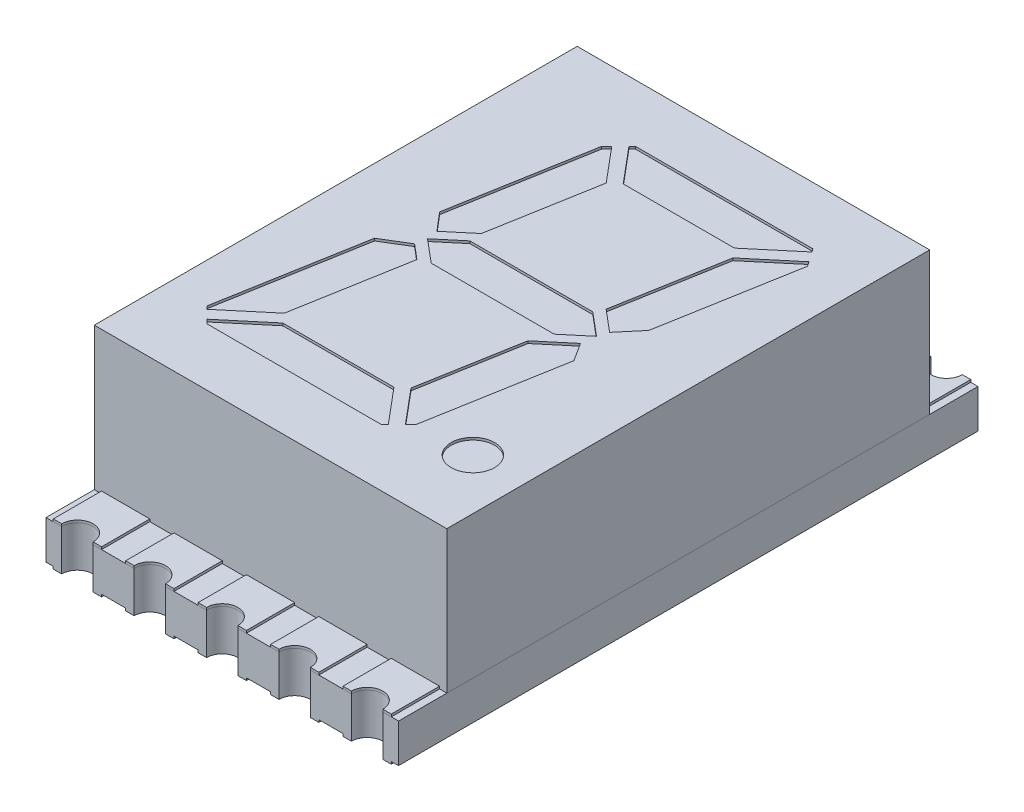
from build123d import *

# Parameters (mm, degrees)
SKETCH1_W          = 7.3
SKETCH1_H          = 10
EXTRUDE1_DEPTH     = 2.95
SKETCH6_R          = 0.45
CUT_EXTRUDE1_DEPTH = 0.05
SKETCH9_W          = 7.3
SKETCH9_H          = 12
EXTRUDE2_DEPTH     = 0.8
EXTRUDE3_DEPTH     = 0.05
EXTRUDE3_2_DEPTH   = 0.05
EXTRUDE3_3_DEPTH   = 0.05
EXTRUDE3_4_DEPTH   = 0.05
EXTRUDE3_5_DEPTH   = 0.05
EXTRUDE3_6_DEPTH   = 0.05
EXTRUDE3_7_DEPTH   = 0.05
EXTRUDE3_8_DEPTH   = 0.05
EXTRUDE3_9_DEPTH   = 0.05
EXTRUDE3_10_DEPTH  = 0.05
SKETCH11_W         = 1
SKETCH11_H         = 1.3
EXTRUDE4_DEPTH     = 0.05
SKETCH10_5_R       = 0.325
CUT_EXTRUDE2_DEPTH = 1.85


with BuildPart() as part:
    # Sketch1 → Extrude1 (new body)
    with BuildSketch(Plane(origin=(0, 0, 0), x_dir=(1, 0, 0), z_dir=(0, 1, 0))):
        Rectangle(SKETCH1_W, SKETCH1_H)
    extrude(amount=-EXTRUDE1_DEPTH)

    # Sketch6 → Cut-Extrude1 (cut)
    with BuildSketch(Plane(origin=(0, 0, 0), x_dir=(-1, 0, 0), z_dir=(0, 1, 0))):
        Polygon((1.497133821, -3.562928938), (1.603616149, -3.456446609), (2.106021692, -0.607163185), (1.786018363, -0.230858463), (1.28606151, -0.650372074), (0.898330642, -2.849303098), align=None)
        Polygon((1.250062758, -3.81), (1.319681867, -3.740380891), (0.706819531, -3.01), (-1.595956803, -3.01), (-2.468328033, -3.742006377), (-2.420718386, -3.81), align=None)
        Polygon((1.792236167, 0.225641106), (2.308170181, 0.539277865), (2.828779838, 3.491801948), (2.77008652, 3.550495267), (1.89771529, 2.818488889), (1.485856892, 0.482723843), align=None)
        Polygon((1.273298563, -0.4), (1.75, 0), (1.273298563, 0.4), (-1.273298563, 0.4), (-1.75, 0), (-1.273298563, -0.4), align=None)
        Polygon((-2.612269884, -3.536436109), (-1.756653705, -2.818488889), (-1.362976227, -0.585832963), (-1.815546448, -0.206081458), (-2.186257722, -0.647877951), (-2.678827782, -3.44138158), align=None)
        Polygon((1.737018387, 3.01), (2.592634566, 3.72794722), (2.510581787, 3.81), (-1.109001174, 3.81), (-1.178620283, 3.740380891), (-0.565757946, 3.01), align=None)
        Polygon((-1.712086694, 0.292894499), (-1.120504838, 0.789290616), (-0.757269057, 2.849303098), (-1.356072236, 3.562928938), (-1.462554564, 3.456446609), (-1.953419115, 0.672615404), align=None)
        with Locations(Location((-2.6, 3.41, 0), (0, 0, 90))):  # turned: the seam where the file's is
            Circle(SKETCH6_R)
    extrude(amount=-CUT_EXTRUDE1_DEPTH, mode=Mode.SUBTRACT)


with BuildPart() as body_2:
    # Sketch9 → Extrude2 (new body)
    with BuildSketch(Plane.XZ.offset(2.95)):
        Rectangle(SKETCH9_W, SKETCH9_H)
    extrude(amount=EXTRUDE2_DEPTH)

    # Sketch11 → Extrude4 (add)
    with BuildSketch(Plane.XZ.offset(3.75)):
        with Locations((-3, 5.35)):
            Rectangle(SKETCH11_W, SKETCH11_H)
        with Locations((-1.5, 5.35)):
            Rectangle(SKETCH11_W, SKETCH11_H)
        with Locations((1.5, 5.35)):
            Rectangle(SKETCH11_W, SKETCH11_H)
        with Locations((0, 5.35)):
            Rectangle(SKETCH11_W, SKETCH11_H)
        with Locations((3, 5.35)):
            Rectangle(SKETCH11_W, SKETCH11_H)
        with Locations((-3, -5.35)):
            Rectangle(SKETCH11_W, SKETCH11_H)
        with Locations((-1.5, -5.35)):
            Rectangle(SKETCH11_W, SKETCH11_H)
        with Locations((0, -5.35)):
            Rectangle(SKETCH11_W, SKETCH11_H)
        with Locations((1.5, -5.35)):
            Rectangle(SKETCH11_W, SKETCH11_H)
        with Locations((3, -5.35)):
            Rectangle(SKETCH11_W, SKETCH11_H)
    extrude(amount=EXTRUDE4_DEPTH)

    # Sketch10_5 → Cut-Extrude2 (cut, through all)
    with BuildSketch(Plane(origin=(0, -2.95, 0), x_dir=(-1, 0, 0), z_dir=(0, 1, 0))):
        with Locations((3, 6)):
            Circle(SKETCH10_5_R)
        with Locations((1.5, 6)):
            Circle(SKETCH10_5_R)
        with Locations((0, 6)):
            Circle(SKETCH10_5_R)
        with Locations((-1.5, 6)):
            Circle(SKETCH10_5_R)
        with Locations((-3, 6)):
            Circle(SKETCH10_5_R)
        with Locations((-3, -6)):
            Circle(SKETCH10_5_R)
        with Locations((-1.5, -6)):
            Circle(SKETCH10_5_R)
        with Locations((0, -6)):
            Circle(SKETCH10_5_R)
        with Locations((1.5, -6)):
            Circle(SKETCH10_5_R)
        with Locations((3, -6)):
            Circle(SKETCH10_5_R)
    extrude(amount=-CUT_EXTRUDE2_DEPTH, mode=Mode.SUBTRACT)


with BuildPart() as body_3:
    # Sketch10 → Extrude3 (new body)
    with BuildSketch(Plane(origin=(0, -2.95, 0), x_dir=(-1, 0, 0), z_dir=(0, 1, 0))):
        with BuildLine():
            Line((2.5, -5), (2.5, -6))
            Line((2.5, -6), (2.675, -6))
            ThreePointArc((2.675, -6), (3, -5.675), (3.325, -6))
            Line((3.325, -6), (3.5, -6))
            Line((3.5, -6), (3.5, -5))
            Line((3.5, -5), (2.5, -5))
        make_face()
    extrude(amount=EXTRUDE3_DEPTH)


with BuildPart() as body_4:
    # Sketch10 → Extrude3 2 (new body)
    with BuildSketch(Plane(origin=(0, -2.95, 0), x_dir=(-1, 0, 0), z_dir=(0, 1, 0))):
        with BuildLine():
            Line((1, -5), (1, -6))
            Line((1, -6), (1.175, -6))
            ThreePointArc((1.175, -6), (1.5, -5.675), (1.825, -6))
            Line((1.825, -6), (2, -6))
            Line((2, -6), (2, -5))
            Line((2, -5), (1, -5))
        make_face()
    extrude(amount=EXTRUDE3_2_DEPTH)


with BuildPart() as body_5:
    # Sketch10 → Extrude3 3 (new body)
    with BuildSketch(Plane(origin=(0, -2.95, 0), x_dir=(-1, 0, 0), z_dir=(0, 1, 0))):
        with BuildLine():
            Line((-0.5, -5), (-0.5, -6))
            Line((-0.5, -6), (-0.325, -6))
            ThreePointArc((-0.325, -6), (0, -5.675), (0.325, -6))
            Line((0.325, -6), (0.5, -6))
            Line((0.5, -6), (0.5, -5))
            Line((0.5, -5), (-0.5, -5))
        make_face()
    extrude(amount=EXTRUDE3_3_DEPTH)


with BuildPart() as body_6:
    # Sketch10 → Extrude3 4 (new body)
    with BuildSketch(Plane(origin=(0, -2.95, 0), x_dir=(-1, 0, 0), z_dir=(0, 1, 0))):
        with BuildLine():
            Line((-2, -5), (-2, -6))
            Line((-2, -6), (-1.825, -6))
            ThreePointArc((-1.825, -6), (-1.5, -5.675), (-1.175, -6))
            Line((-1.175, -6), (-1, -6))
            Line((-1, -6), (-1, -5))
            Line((-1, -5), (-2, -5))
        make_face()
    extrude(amount=EXTRUDE3_4_DEPTH)


with BuildPart() as body_7:
    # Sketch10 → Extrude3 5 (new body)
    with BuildSketch(Plane(origin=(0, -2.95, 0), x_dir=(-1, 0, 0), z_dir=(0, 1, 0))):
        with BuildLine():
            Line((-2.5, -5), (-3.5, -5))
            Line((-3.5, -5), (-3.5, -6))
            Line((-3.5, -6), (-3.325, -6))
            ThreePointArc((-3.325, -6), (-3, -5.675), (-2.675, -6))
            Line((-2.675, -6), (-2.5, -6))
            Line((-2.5, -6), (-2.5, -5))
        make_face()
    extrude(amount=EXTRUDE3_5_DEPTH)


with BuildPart() as body_8:
    # Sketch10 → Extrude3 6 (new body)
    with BuildSketch(Plane(origin=(0, -2.95, 0), x_dir=(-1, 0, 0), z_dir=(0, 1, 0))):
        with BuildLine():
            Line((2.5, 5), (3.5, 5))
            Line((3.5, 5), (3.5, 6))
            Line((3.5, 6), (3.325, 6))
            ThreePointArc((3.325, 6), (3, 5.675), (2.675, 6))
            Line((2.675, 6), (2.5, 6))
            Line((2.5, 6), (2.5, 5))
        make_face()
    extrude(amount=EXTRUDE3_6_DEPTH)


with BuildPart() as body_9:
    # Sketch10 → Extrude3 7 (new body)
    with BuildSketch(Plane(origin=(0, -2.95, 0), x_dir=(-1, 0, 0), z_dir=(0, 1, 0))):
        with BuildLine():
            Line((2, 5), (2, 6))
            Line((2, 6), (1.825, 6))
            ThreePointArc((1.825, 6), (1.5, 5.675), (1.175, 6))
            Line((1.175, 6), (1, 6))
            Line((1, 6), (1, 5))
            Line((1, 5), (2, 5))
        make_face()
    extrude(amount=EXTRUDE3_7_DEPTH)


with BuildPart() as body_10:
    # Sketch10 → Extrude3 8 (new body)
    with BuildSketch(Plane(origin=(0, -2.95, 0), x_dir=(-1, 0, 0), z_dir=(0, 1, 0))):
        with BuildLine():
            Line((0.5, 5), (0.5, 6))
            Line((0.5, 6), (0.325, 6))
            ThreePointArc((0.325, 6), (0, 5.675), (-0.325, 6))
            Line((-0.325, 6), (-0.5, 6))
            Line((-0.5, 6), (-0.5, 5))
            Line((-0.5, 5), (0.5, 5))
        make_face()
    extrude(amount=EXTRUDE3_8_DEPTH)


with BuildPart() as body_11:
    # Sketch10 → Extrude3 9 (new body)
    with BuildSketch(Plane(origin=(0, -2.95, 0), x_dir=(-1, 0, 0), z_dir=(0, 1, 0))):
        with BuildLine():
            Line((-1, 5), (-1, 6))
            Line((-1, 6), (-1.175, 6))
            ThreePointArc((-1.175, 6), (-1.5, 5.675), (-1.825, 6))
            Line((-1.825, 6), (-2, 6))
            Line((-2, 6), (-2, 5))
            Line((-2, 5), (-1, 5))
        make_face()
    extrude(amount=EXTRUDE3_9_DEPTH)


with BuildPart() as body_12:
    # Sketch10 → Extrude3 10 (new body)
    with BuildSketch(Plane(origin=(0, -2.95, 0), x_dir=(-1, 0, 0), z_dir=(0, 1, 0))):
        with BuildLine():
            Line((-2.5, 5), (-2.5, 6))
            Line((-2.5, 6), (-2.675, 6))
            ThreePointArc((-2.675, 6), (-3, 5.675), (-3.325, 6))
            Line((-3.325, 6), (-3.5, 6))
            Line((-3.5, 6), (-3.5, 5))
            Line((-3.5, 5), (-2.5, 5))
        make_face()
    extrude(amount=EXTRUDE3_10_DEPTH)


solid = Compound([part.part, body_2.part, body_3.part, body_4.part, body_5.part, body_6.part, body_7.part, body_8.part, body_9.part, body_10.part, body_11.part, body_12.part])
